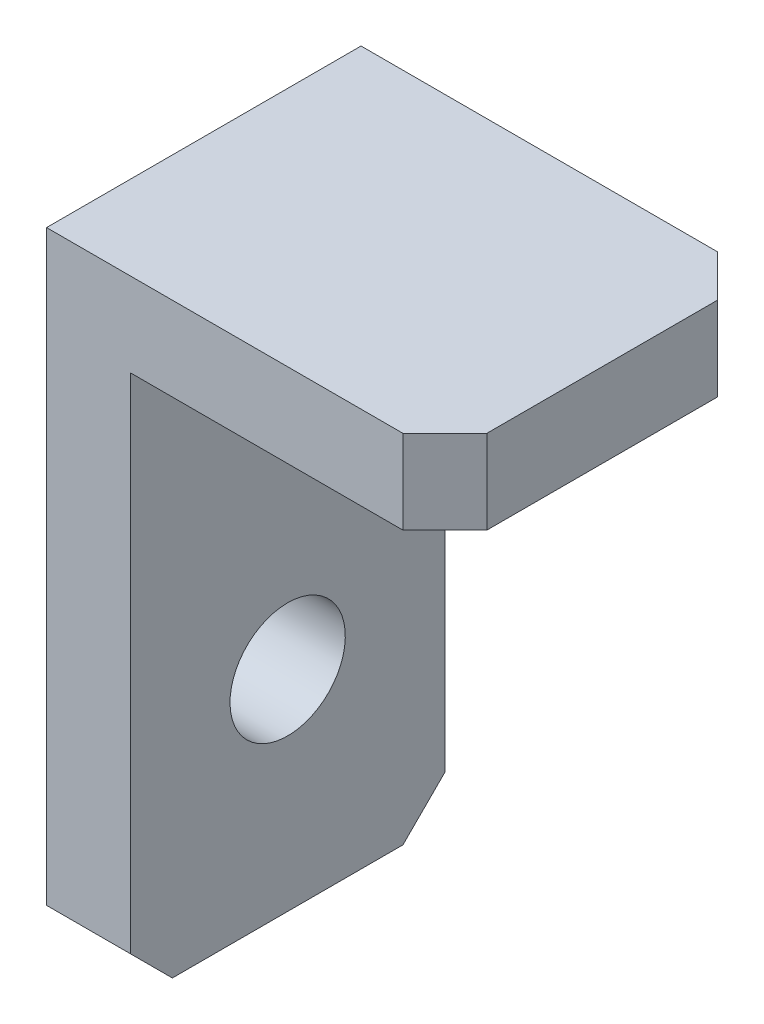
from build123d import *

# Parameters (mm, degrees)
BOSS_EXTRUDE1_DEPTH = 15
CUT_EXTRUDE1_REACH  = 6
SKETCH2_R           = 2.75
CHAMFER1_SIZE       = 2


with BuildPart() as part:
    # Sketch1 → Boss-Extrude1 (new body)
    with BuildSketch(Plane.XY):
        Polygon((0, 0), (19, 0), (19, -4), (4, -4), (4, -30), (0, -30), align=None)
    extrude(amount=BOSS_EXTRUDE1_DEPTH)

    # Sketch2 → Cut-Extrude1 (cut, up to next)
    with BuildSketch(Plane(origin=(4, 0, 0), x_dir=(0, 0, -1), z_dir=(1, 0, 0)), mode=Mode.PRIVATE) as cut_extrude1_sk1:
        with Locations((-7.5, -20)):
            Circle(SKETCH2_R)
    cut_extrude1_tool1 = extrude(cut_extrude1_sk1.sketch, amount=-CUT_EXTRUDE1_REACH, mode=Mode.PRIVATE) & part.part
    add(cut_extrude1_tool1.solids().sort_by_distance((4, -20, 7.5))[0], mode=Mode.SUBTRACT)

    # Chamfer1
    chamfer1_edges = [part.edges().sort_by_distance(p)[0] for p in [
        (19, -2, 15),
        (19, -2, 0),
        (2, -30, 15),
        (2, -30, 0),
    ]]
    chamfer(chamfer1_edges, length=CHAMFER1_SIZE)


solid = part.part
